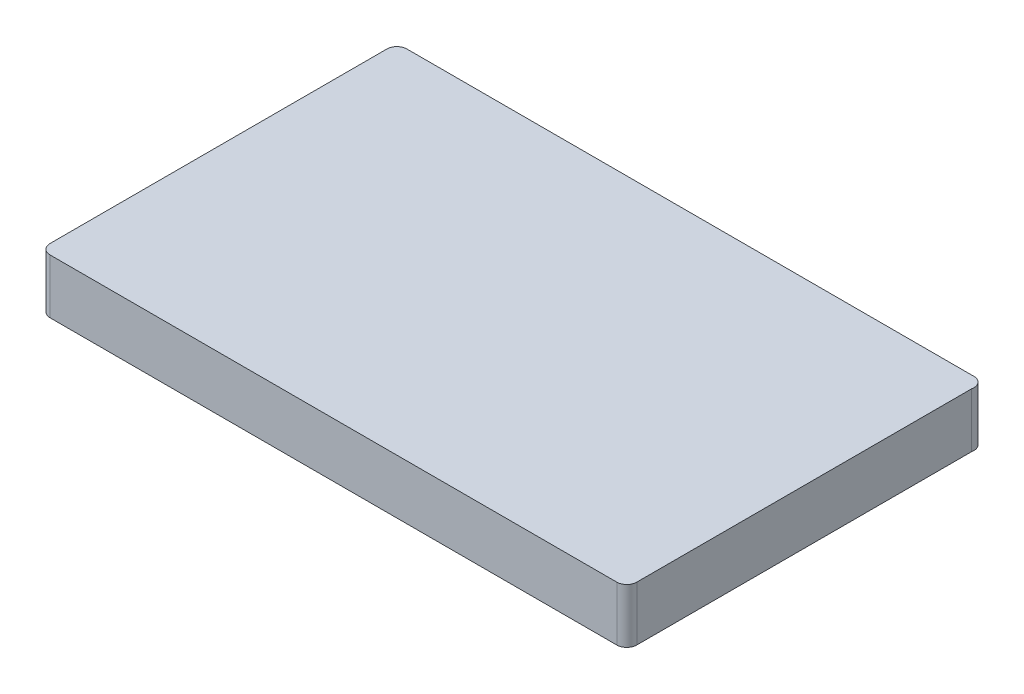
from build123d import *

# Parameters (mm, degrees)
BOSS_EXTRUDE1_DEPTH = 13.65


with BuildPart() as part:
    # Sketch1 → Boss-Extrude1 (new body)
    with BuildSketch(Plane(origin=(0, 0, 0), x_dir=(1, 0, 0), z_dir=(0, 1, 0))):
        with BuildLine():
            Line((71, -44.7), (-71, -44.7))
            ThreePointArc((-71, -44.7), (-72.767766953, -43.967766953), (-73.5, -42.2))
            Line((-73.5, -42.2), (-73.5, 42.2))
            ThreePointArc((-73.5, 42.2), (-72.767766953, 43.967766953), (-71, 44.7))
            Line((-71, 44.7), (70.716721676, 44.7))
            ThreePointArc((70.716721676, 44.7), (72.879328688, 43.928173367), (73.5, 41.717437615))
            Line((73.5, 41.717437615), (73.5, -42.2))
            ThreePointArc((73.5, -42.2), (72.767766953, -43.967766953), (71, -44.7))
        make_face()
    extrude(amount=BOSS_EXTRUDE1_DEPTH)


solid = part.part
